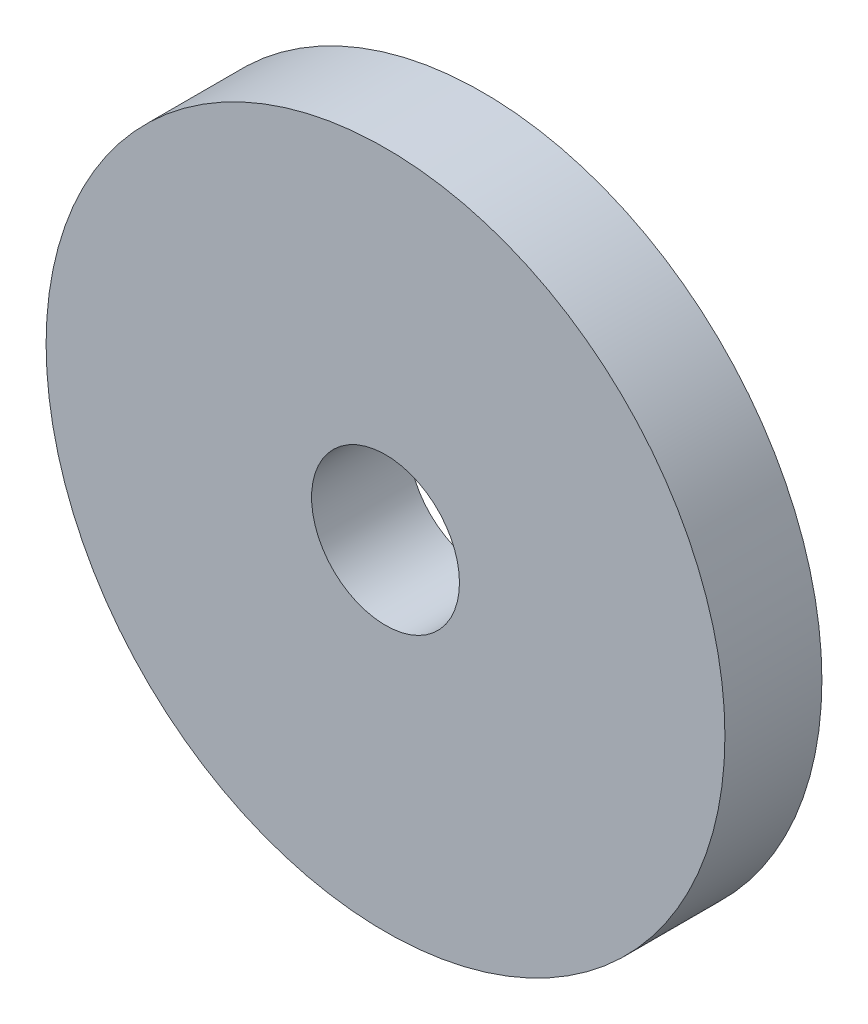
from build123d import *

# Parameters (mm, degrees)
SKETCH_1_R      = 7
SKETCH_1_R_2    = 1.525
EXTRUDE_1_DEPTH = 2


with BuildPart() as part:
    # 草图1 → 凸台-拉伸1 (new body)
    with BuildSketch(Plane.XY):
        Circle(SKETCH_1_R)
        Circle(SKETCH_1_R_2, mode=Mode.SUBTRACT)
    extrude(amount=EXTRUDE_1_DEPTH)


solid = part.part
